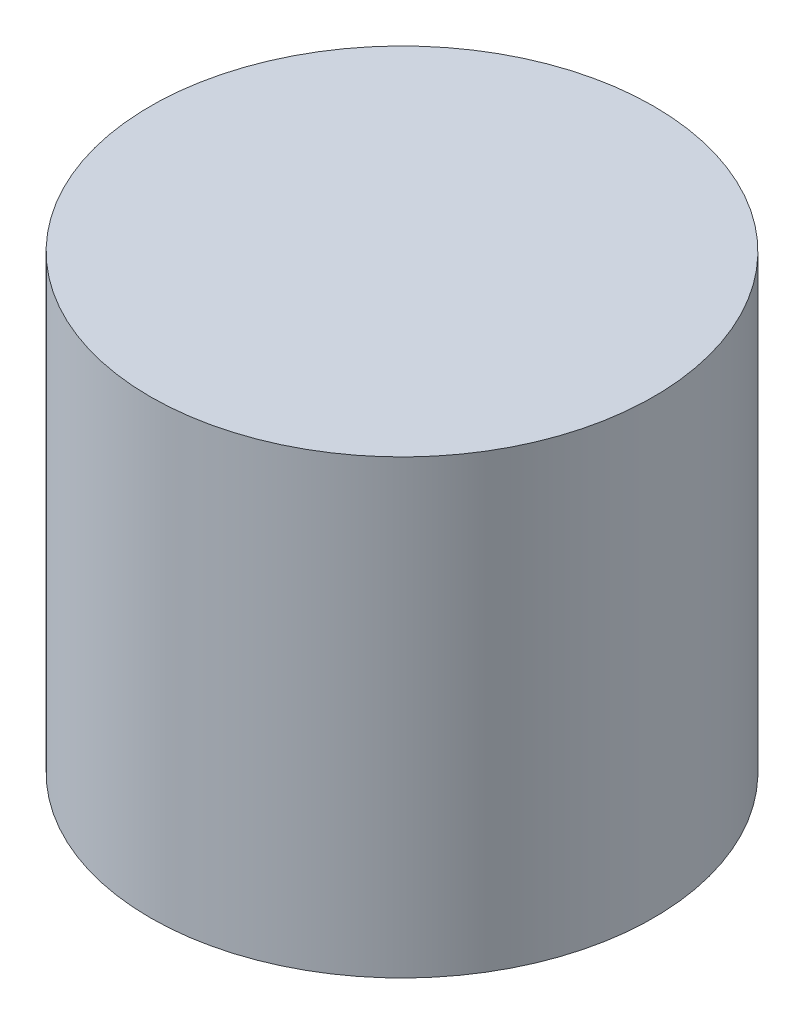
from build123d import *

# Parameters (mm, degrees)
SKETCH1_R           = 7.25
BOSS_EXTRUDE1_DEPTH = 13
SKETCH2_R           = 5.25
CUT_EXTRUDE1_DEPTH  = 11


with BuildPart() as part:
    # Sketch1 → Boss-Extrude1 (new body)
    with BuildSketch(Plane(origin=(0, 0, 0), x_dir=(1, 0, 0), z_dir=(0, 1, 0))):
        Circle(SKETCH1_R)
    extrude(amount=BOSS_EXTRUDE1_DEPTH)

    # Sketch2 → Cut-Extrude1 (cut)
    with BuildSketch(Plane(origin=(0, 0, 0), x_dir=(-1, 0, 0), z_dir=(0, -1, 0))):
        Circle(SKETCH2_R)
    extrude(amount=-CUT_EXTRUDE1_DEPTH, mode=Mode.SUBTRACT)


solid = part.part
